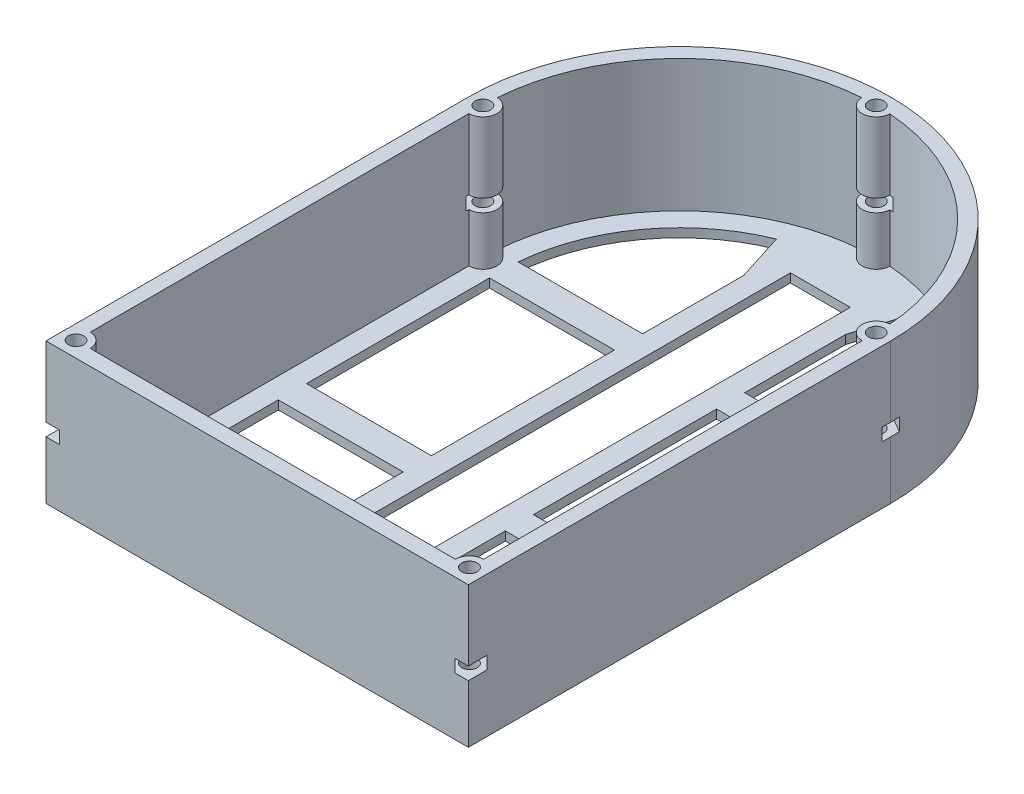
from build123d import *

# Parameters (mm, degrees)
SKETCH1_R           = 1.1
BOSS_EXTRUDE1_DEPTH = 20
SKETCH2_W           = 8.5
SKETCH2_H           = 70
SKETCH2_W_2         = 17.75
SKETCH2_H_2         = 26
BOSS_EXTRUDE2_DEPTH = 1.25
CUT_EXTRUDE1_START  = -10
CUT_EXTRUDE1_DEPTH  = 1.8


with BuildPart() as part:
    # Sketch1 → Boss-Extrude1 (new body)
    with BuildSketch(Plane(origin=(0, 0, 0), x_dir=(1, 0, 0), z_dir=(0, 1, 0))):
        with BuildLine():
            Line((-30, 0), (-30, -60))
            Line((-30, -60), (30, -60))
            Line((30, -60), (30, 0))
            ThreePointArc((30, 0), (0, 30), (-30, 0))
        make_face()
        with Locations((27.94, 0)):
            Circle(SKETCH1_R, mode=Mode.SUBTRACT)
        with Locations((-27.94, 0)):
            Circle(SKETCH1_R, mode=Mode.SUBTRACT)
        with Locations((0, 27.94)):
            Circle(SKETCH1_R, mode=Mode.SUBTRACT)
        with Locations((-27.94, -57.785)):
            Circle(SKETCH1_R, mode=Mode.SUBTRACT)
        with Locations((27.94, -57.785)):
            Circle(SKETCH1_R, mode=Mode.SUBTRACT)
        with BuildLine():
            Line((27.94, -55.785), (27.94, -2))
            ThreePointArc((27.94, -2), (25.940320377, -0.035796715), (27.868418039, 1.998718595))
            ThreePointArc((27.868418039, 1.998718595), (19.756563466, 19.756563466), (1.998718595, 27.868418039))
            ThreePointArc((1.998718595, 27.868418039), (0, 25.94), (-1.998718595, 27.868418039))
            ThreePointArc((-1.998718595, 27.868418039), (-19.756563466, 19.756563466), (-27.868418039, 1.998718595))
            ThreePointArc((-27.868418039, 1.998718595), (-25.940320377, -0.035796715), (-27.94, -2))
            Line((-27.94, -2), (-27.94, -55.785))
            ThreePointArc((-27.94, -55.785), (-26.525786438, -56.370786438), (-25.94, -57.785))
            Line((-25.94, -57.785), (25.94, -57.785))
            ThreePointArc((25.94, -57.785), (26.525786438, -56.370786438), (27.94, -55.785))
        make_face(mode=Mode.SUBTRACT)
    extrude(amount=-BOSS_EXTRUDE1_DEPTH)

    # Sketch2 → Boss-Extrude2 (add)
    with BuildSketch(Plane.XZ.offset(20)):
        with BuildLine():
            Line((30, 0), (30, 60))
            Line((30, 60), (-30, 60))
            Line((-30, 60), (-30, 0))
            ThreePointArc((-30, 0), (0, -30), (30, 0))
        make_face()
        Polygon((-7.25, 53), (-7.25, 32), (-25, 32), (-25, 55), (-7.25, 55), align=None, mode=Mode.SUBTRACT)
        with Locations((0, 15)):
            Rectangle(SKETCH2_W, SKETCH2_H, mode=Mode.SUBTRACT)
        Polygon((7.25, 53), (7.25, 32), (25, 32), (25, 55), (7.25, 55), align=None, mode=Mode.SUBTRACT)
        with Locations((16.125, 15)):
            Rectangle(SKETCH2_W_2, SKETCH2_H_2, mode=Mode.SUBTRACT)
        with BuildLine():
            Line((-7.25, -16.347418764), (-9.399268665, -23.165788322))
            ThreePointArc((-9.399268665, -23.165788322), (-20.160567843, -14.783487553), (-24.919871589, -2))
            Line((-24.919871589, -2), (-7.25, -2))
            Line((-7.25, -2), (-7.25, -16.347418764))
        make_face(mode=Mode.SUBTRACT)
        with BuildLine():
            Line((7.25, -16.347418764), (9.399268665, -23.165788322))
            ThreePointArc((9.399268665, -23.165788322), (20.160567843, -14.783487553), (24.919871589, -2))
            Line((24.919871589, -2), (7.25, -2))
            Line((7.25, -2), (7.25, -16.347418764))
        make_face(mode=Mode.SUBTRACT)
        with Locations((-16.125, 15)):
            Rectangle(SKETCH2_W_2, SKETCH2_H_2, mode=Mode.SUBTRACT)
    extrude(amount=-BOSS_EXTRUDE2_DEPTH)

    # Sketch3 → Cut-Extrude1 (cut)
    with BuildSketch(Plane(origin=(0, 0, 0), x_dir=(1, 0, 0), z_dir=(0, 1, 0)).offset(CUT_EXTRUDE1_START)):
        Polygon((2.424871131, 27.94), (1.212435565, 30.04), (-1.212435565, 30.04), (-2.424871131, 27.94), (-2.923440006, 27.076453377), (-1.212435565, 25.84), (1.212435565, 25.84), (2.664841123, 27.524359781), align=None)
        Polygon((27.94, -2.424871131), (30.04, -1.212435565), (30.04, 1.212435565), (27.94, 2.424871131), (27.29756517, 2.795781052), (25.84, 1.212435565), (25.84, -1.212435565), align=None)
        Polygon((30.28224565, -58.412602831), (29.65464282, -56.07035718), (27.312397169, -55.44275435), (25.59775435, -57.157397169), (26.22535718, -59.49964282), (28.567602831, -60.12724565), (30.909848481, -60.754848481), align=None)
        Polygon((-25.59775435, -57.157397169), (-27.312397169, -55.44275435), (-29.65464282, -56.07035718), (-30.28224565, -58.412602831), (-30.909848481, -60.754848481), (-28.567602831, -60.12724565), (-26.22535718, -59.49964282), align=None)
        Polygon((-30.04, 1.212435565), (-30.04, -1.212435565), (-27.94, -2.424871131), (-25.84, -1.212435565), (-25.84, 1.212435565), (-27.443113573, 2.711748643), (-27.94, 2.424871131), align=None)
    extrude(amount=-CUT_EXTRUDE1_DEPTH, mode=Mode.SUBTRACT)


solid = part.part
